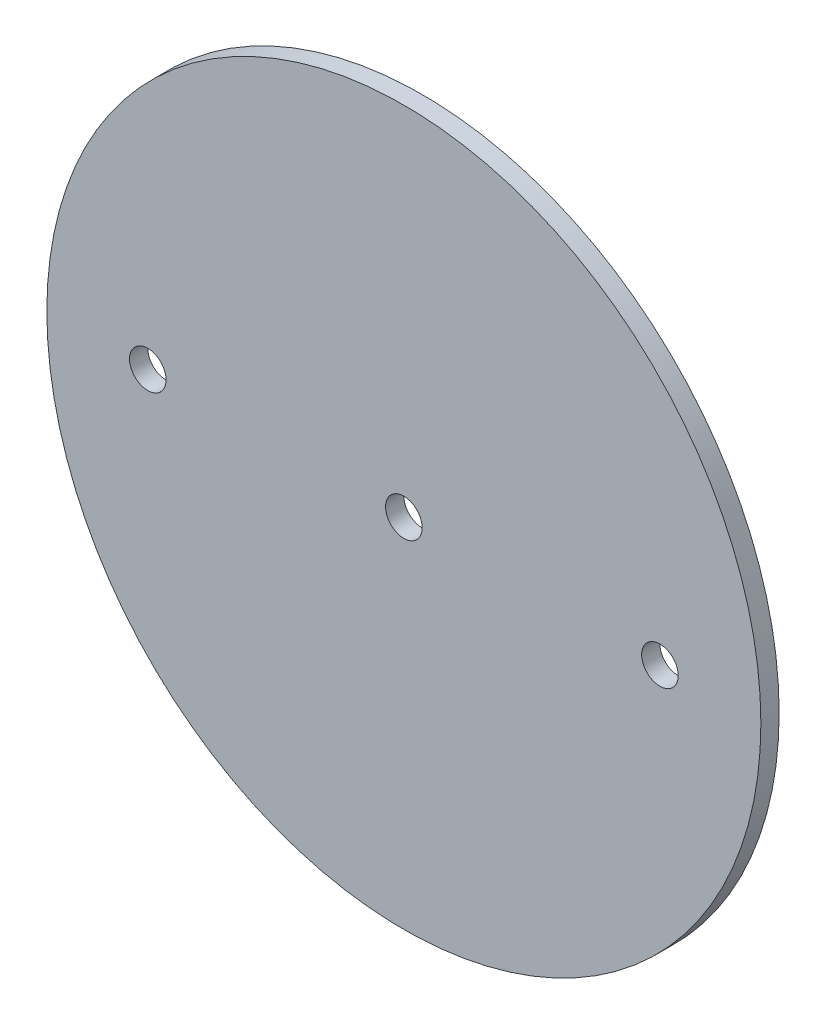
from build123d import *

# Parameters (mm, degrees)
SKETCH1_R                   = 61.976
BOSS_EXTRUDE1_DEPTH         = 1.5875
F_1_4_0_25_DIAMETER_HOLE1_D = 6.35


with BuildPart() as part:
    # Sketch1 → Boss-Extrude1 (new body, symmetric)
    with BuildSketch(Plane.XY):
        Circle(SKETCH1_R)
    extrude(amount=BOSS_EXTRUDE1_DEPTH, both=True)

    # 1/4 (0.25) Diameter Hole1 (through all)
    with Locations(Plane.XY.offset(1.5875)):
        with Locations((-44.45, 0), (0, 0), (44.45, 0)):
            Hole(F_1_4_0_25_DIAMETER_HOLE1_D / 2)


solid = part.part
